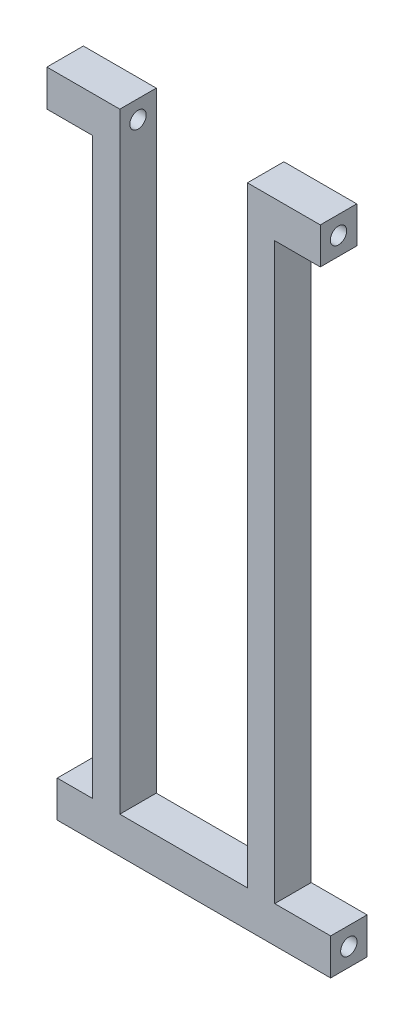
from build123d import *

# Parameters (mm, degrees)
CROQUIS8_W                   = 6
CROQUIS8_H                   = 126
CROQUIS8_W_2                 = 60
CROQUIS8_H_2                 = 8
SALIENTE_EXTRUIR1_DEPTH      = 8
TALADRO_DE_MARGEN_PARA_M31_D = 3.6
TALADRO_DE_MARGEN_PARA_M32_D = 3.6


with BuildPart() as part:
    # Croquis8 → Saliente-Extruir1 (new body)
    with BuildSketch(Plane.XY):
        Polygon((7.730954987, 134), (13.730954987, 134), (13.730954987, 142), (-2.269045013, 142), (-2.269045013, 134), align=None)
        with Locations((10.730954987, 71)):
            Rectangle(CROQUIS8_W, CROQUIS8_H)
        Polygon((41.730954987, 142), (41.730954987, 134), (47.730954987, 134), (57.730954987, 134), (57.730954987, 142), align=None)
        with Locations((44.730954987, 71)):
            Rectangle(CROQUIS8_W, CROQUIS8_H)
        with Locations((30, 4)):
            Rectangle(CROQUIS8_W_2, CROQUIS8_H_2)
    extrude(amount=SALIENTE_EXTRUIR1_DEPTH)

    # Taladro de margen para M31 (through all)
    with Locations(Plane(origin=(57.730954987, 0, 0), x_dir=(0, 0, -1), z_dir=(1, 0, 0))):
        with Locations((-4, 138)):
            Hole(TALADRO_DE_MARGEN_PARA_M31_D / 2)

    # Taladro de margen para M32 (through all)
    with Locations(Plane(origin=(60, 0, 0), x_dir=(0, 0, -1), z_dir=(1, 0, 0))):
        with Locations((-4, 4)):
            Hole(TALADRO_DE_MARGEN_PARA_M32_D / 2)


solid = part.part
